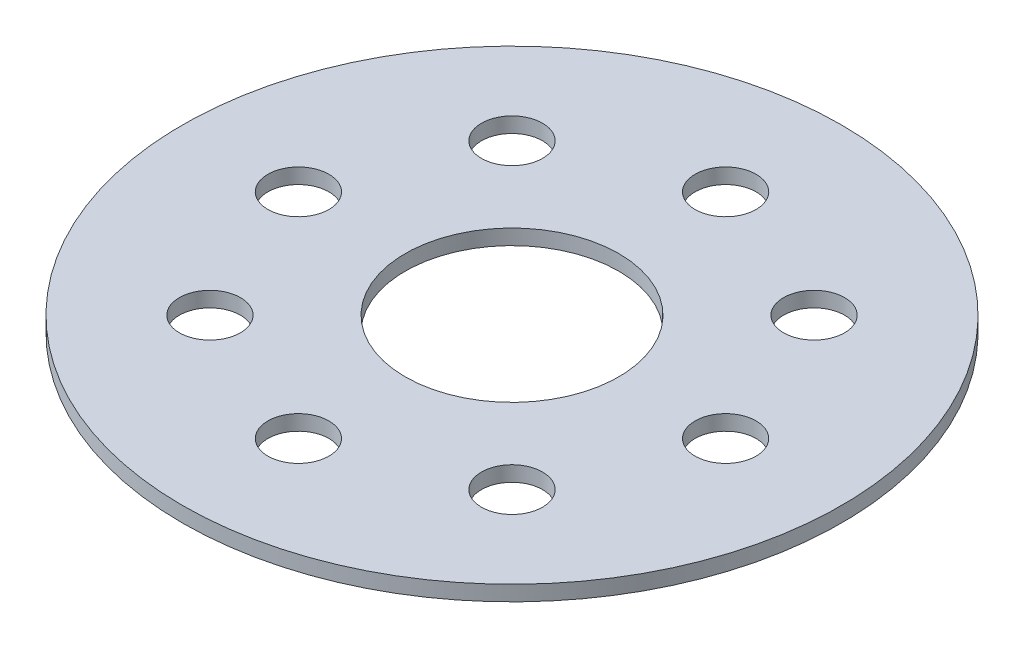
from build123d import *

# Parameters (mm, degrees)
SKETCH1_R           = 68.58
SKETCH1_R_2         = 22.225
BOSS_EXTRUDE1_DEPTH = 3.175
SKETCH2_R           = 6.35
CUT_EXTRUDE1_DEPTH  = 3.175
CIRPATTERN1_COUNT   = 8


with BuildPart() as part:
    # Sketch1 → Boss-Extrude1 (new body)
    with BuildSketch(Plane(origin=(0, 0, 0), x_dir=(1, 0, 0), z_dir=(0, 1, 0))):
        Circle(SKETCH1_R)
        Circle(SKETCH1_R_2, mode=Mode.SUBTRACT)
    extrude(amount=BOSS_EXTRUDE1_DEPTH)

    # Sketch2 → Cut-Extrude1 (cut)
    with BuildSketch(Plane(origin=(0, 3.175, 0), x_dir=(1, 0, 0), z_dir=(0, 1, 0))):
        with Locations((0, 44.45)):
            Circle(SKETCH2_R)
    cut_extrude1 = extrude(amount=-CUT_EXTRUDE1_DEPTH, mode=Mode.SUBTRACT)

    # CirPattern1: Cut-Extrude1 ×8 about axis
    cirpattern1_axis = Axis((0, 0, 0), (0, 1, 0))
    for i in range(1, CIRPATTERN1_COUNT):
        add(cut_extrude1.rotate(cirpattern1_axis, i * 360 / CIRPATTERN1_COUNT), mode=Mode.SUBTRACT)


solid = part.part
